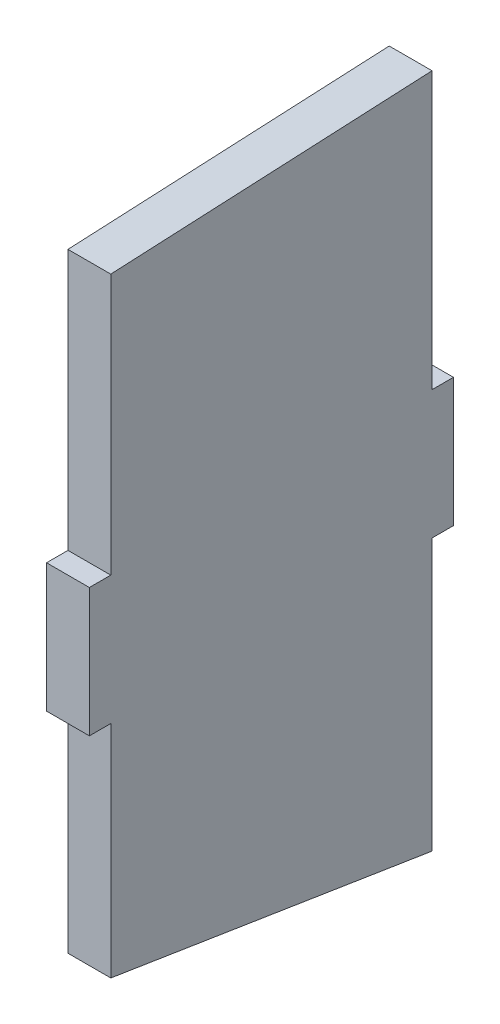
from build123d import *

# Parameters (mm, degrees)
SKETCH1_W           = 12.7
SKETCH1_H           = 76.2
SKETCH1_W_2         = 190.5
BOSS_EXTRUDE1_DEPTH = 25.4


with BuildPart() as part:
    # Sketch1 → Boss-Extrude1 (new body)
    with BuildSketch(Plane(origin=(0, 0, 0), x_dir=(0, 0, -1), z_dir=(1, 0, 0))):
        Polygon((95.25, 201.879837032), (-95.25, 192.69579571), (-95.25, 38.1), (95.25, 38.1), align=None)
        with Locations((101.6, 0)):
            Rectangle(SKETCH1_W, SKETCH1_H)
        Rectangle(SKETCH1_W_2, SKETCH1_H)
        with Locations((-101.6, 0)):
            Rectangle(SKETCH1_W, SKETCH1_H)
        Polygon((95.25, -38.1), (-95.25, -38.1), (-95.25, -168.80022374), (95.25, -198.895286486), align=None)
    extrude(amount=BOSS_EXTRUDE1_DEPTH)


solid = part.part
